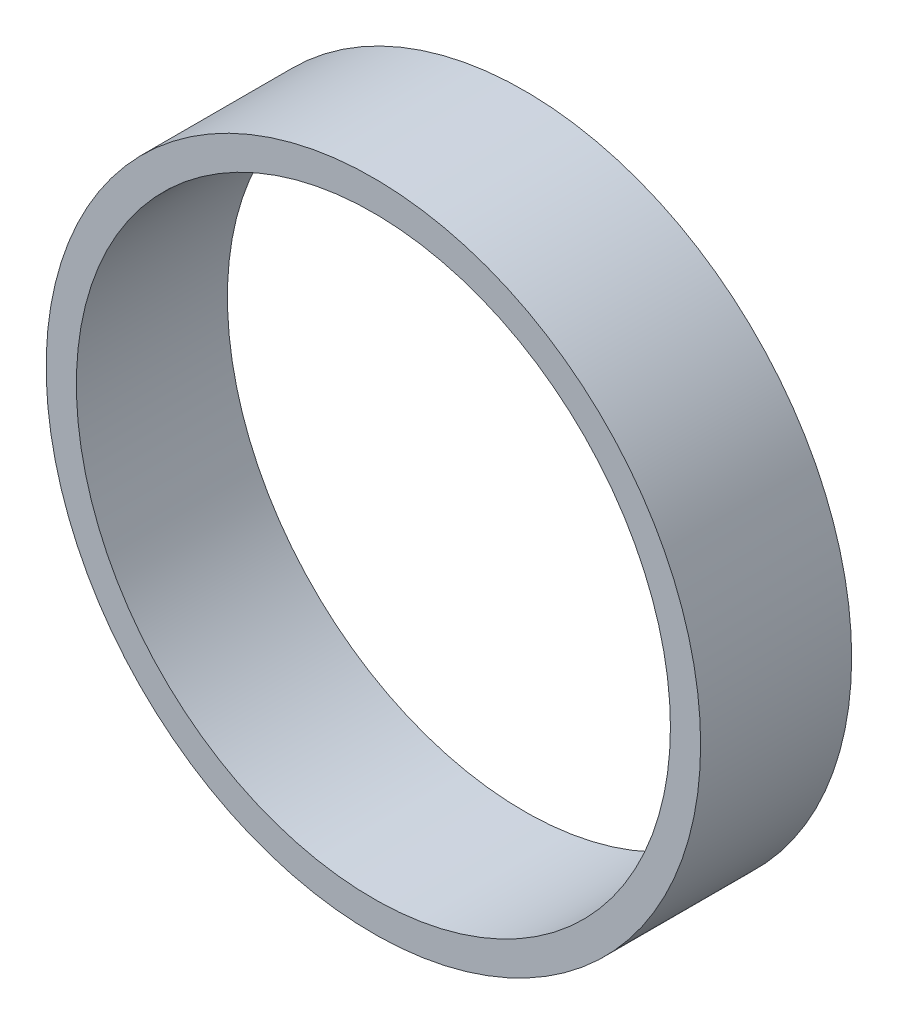
from build123d import *

# Parameters (mm, degrees)
ESQUISSE1_R        = 32.5
ESQUISSE1_R_2      = 29.5
BOSS_EXTRU_1_DEPTH = 15


with BuildPart() as part:
    # Esquisse1 → Boss.-Extru.1 (new body)
    with BuildSketch(Plane.XY):
        Circle(ESQUISSE1_R)
        Circle(ESQUISSE1_R_2, mode=Mode.SUBTRACT)
    extrude(amount=BOSS_EXTRU_1_DEPTH)


solid = part.part
